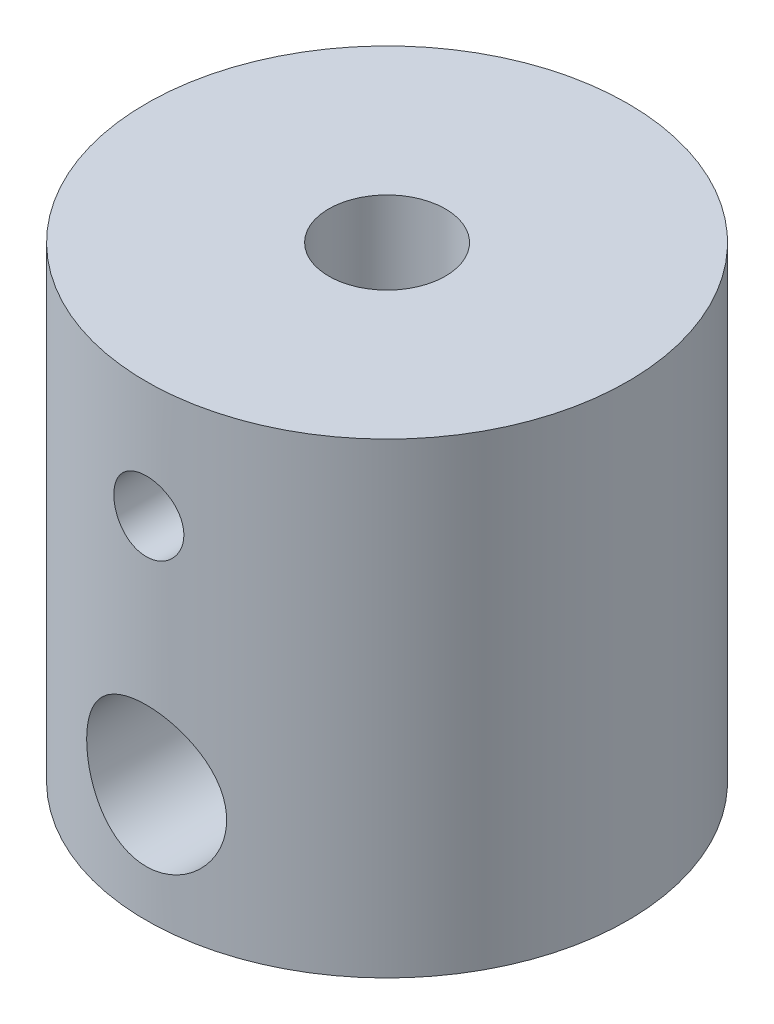
from build123d import *

# Parameters (mm, degrees)
SKETCH2_R          = 3
SKETCH2_R_2        = 1.5
CUT_EXTRUDE1_DEPTH = 11.31875


with BuildPart() as part:
    # Sketch1 → Revolve1 (revolve)
    with BuildSketch(Plane.XY):
        Polygon((-2.5, 20), (-10.31875, 20), (-10.31875, 0), (-5, 0), (-5, 10), (-2.5, 10), align=None)
    revolve(axis=Axis((0, 0, 0), (0, 1, 0)))

    # Sketch2 → Cut-Extrude1 (cut, through all)
    with BuildSketch(Plane.XY):
        with Locations((0, 5)):
            Circle(SKETCH2_R)
        with Locations((0, 15)):
            Circle(SKETCH2_R_2)
    extrude(amount=CUT_EXTRUDE1_DEPTH, mode=Mode.SUBTRACT)


solid = part.part
